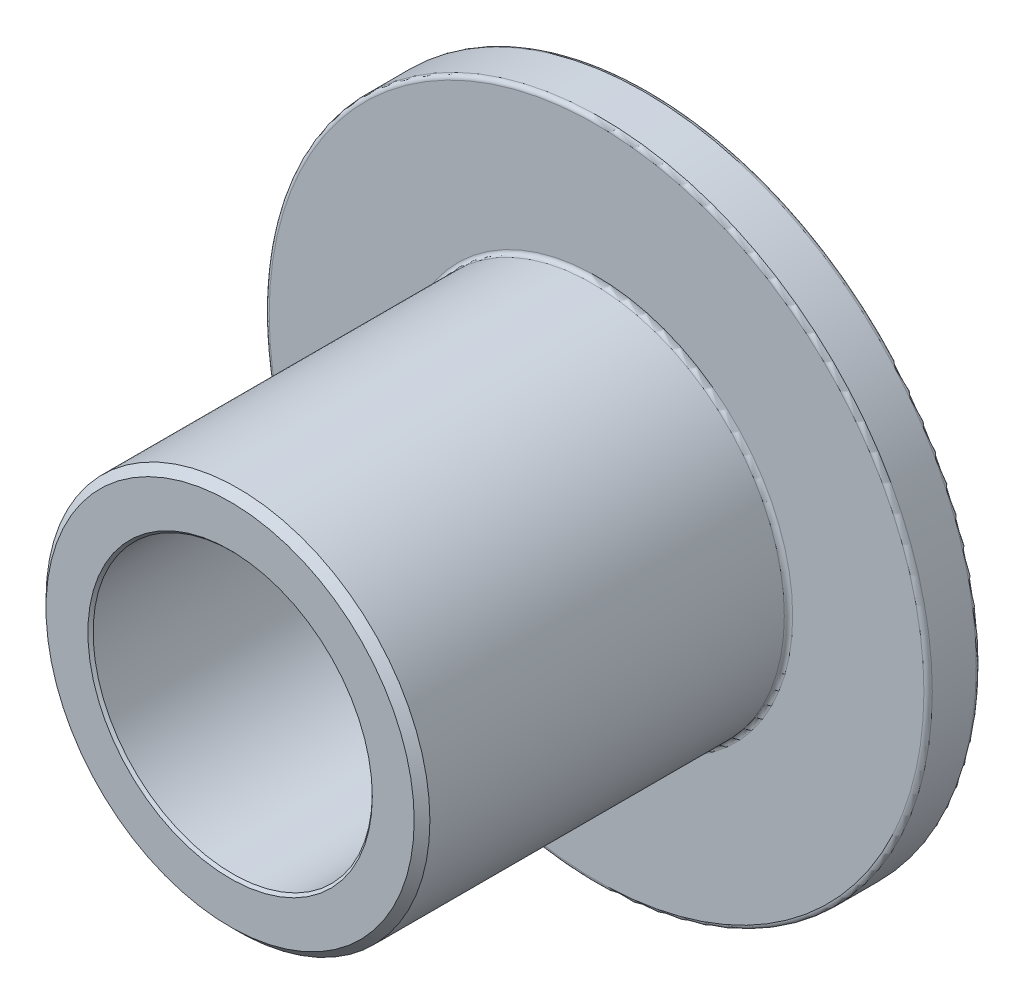
from build123d import *

# Parameters (mm, degrees)
CHAMFER1_SIZE = 0.1125
CHAMFER2_SIZE = 0.0375
FILLET1_R     = 0.06


with BuildPart() as part:
    # Sketch3 → Revolve1 (revolve)
    with BuildSketch(Plane(origin=(0, 0, 0), x_dir=(0, 0, -1), z_dir=(1, 0, 0))):
        Polygon((3, -4.75), (2.25, -4.75), (2.25, -2.75), (-3, -2.75), (-3, -2), (3, -2), align=None)
    revolve(axis=Axis((0, 0, 3), (0, 0, -1)))

    # Chamfer1
    chamfer1_edges = [part.edges().sort_by_distance(p)[0] for p in [
        (0, 2.75, 3),
    ]]
    chamfer(chamfer1_edges, length=CHAMFER1_SIZE)

    # Chamfer2
    chamfer2_edges = [part.edges().sort_by_distance(p)[0] for p in [
        (0, 2, -3),
        (0, 2, 3),
    ]]
    chamfer(chamfer2_edges, length=CHAMFER2_SIZE)

    # Fillet1
    fillet1_edges = [part.edges().sort_by_distance(p)[0] for p in [
        (0, 2.75, -2.25),
        (0, 4.75, -2.25),
        (0, 4.75, -3),
    ]]
    fillet(fillet1_edges, radius=FILLET1_R)


solid = part.part
